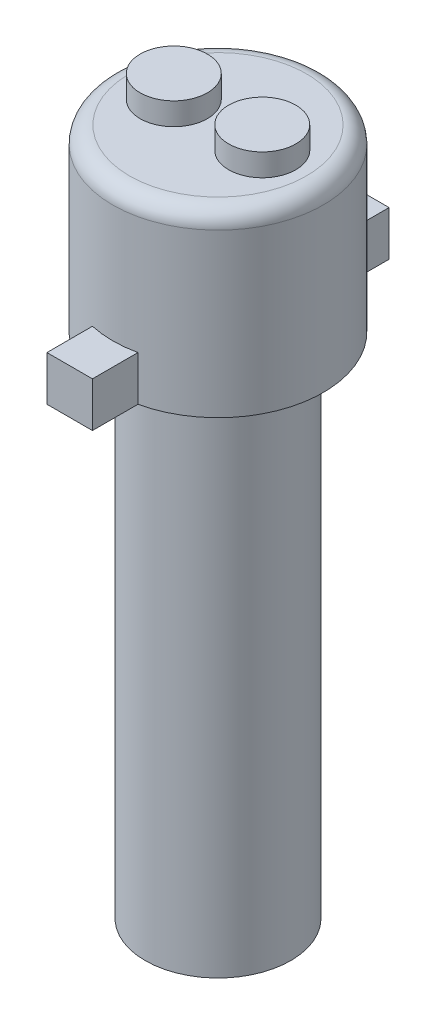
from build123d import *

# Parameters (mm, degrees)
SKETCH1_R           = 3.25
BOSS_EXTRUDE1_DEPTH = 22.686
SKETCH6_R           = 4.7
BOSS_EXTRUDE2_DEPTH = 8
FILLET2_R           = 0.75
SKETCH7_R           = 1.5
BOSS_EXTRUDE3_DEPTH = 1
BOSS_EXTRUDE4_DEPTH = 2


with BuildPart() as part:
    # Sketch1 → Boss-Extrude1 (new body)
    with BuildSketch(Plane(origin=(0, 0, 0), x_dir=(1, 0, 0), z_dir=(0, 1, 0))):
        Circle(SKETCH1_R)
    extrude(amount=BOSS_EXTRUDE1_DEPTH)

    # Sketch6 → Boss-Extrude2 (add)
    with BuildSketch(Plane(origin=(0, 22.686, 0), x_dir=(1, 0, 0), z_dir=(0, 1, 0))):
        Circle(SKETCH6_R)
    extrude(amount=BOSS_EXTRUDE2_DEPTH)

    # Fillet2
    fillet2_edges = [part.edges().sort_by_distance(p)[0] for p in [
        (-4.7, 30.686, 0),
    ]]
    fillet(fillet2_edges, radius=FILLET2_R)

    # Sketch7 → Boss-Extrude3 (add)
    with BuildSketch(Plane(origin=(0, 30.686, 0), x_dir=(1, 0, 0), z_dir=(0, 1, 0))):
        with Locations((-1.975, 0)):
            Circle(SKETCH7_R)
        with Locations((1.975, 0)):
            Circle(SKETCH7_R)
    extrude(amount=BOSS_EXTRUDE3_DEPTH)

    # Sketch8 → Boss-Extrude4 (add)
    with BuildSketch(Plane.XZ.offset(-22.686)):
        with BuildLine():
            Line((-1.016, 4.588871757), (-1.016, 6.620871757))
            Line((-1.016, 6.620871757), (1.016, 6.620871757))
            Line((1.016, 6.620871757), (1.016, 4.588871757))
            ThreePointArc((1.016, 4.588871757), (0, 4.7), (-1.016, 4.588871757))
        make_face()
        with BuildLine():
            Line((1.016, -6.620871757), (1.016, -4.588871757))
            ThreePointArc((1.016, -4.588871757), (0, -4.7), (-1.016, -4.588871757))
            Line((-1.016, -4.588871757), (-1.016, -6.620871757))
            Line((-1.016, -6.620871757), (1.016, -6.620871757))
        make_face()
    extrude(amount=-BOSS_EXTRUDE4_DEPTH)


solid = part.part
